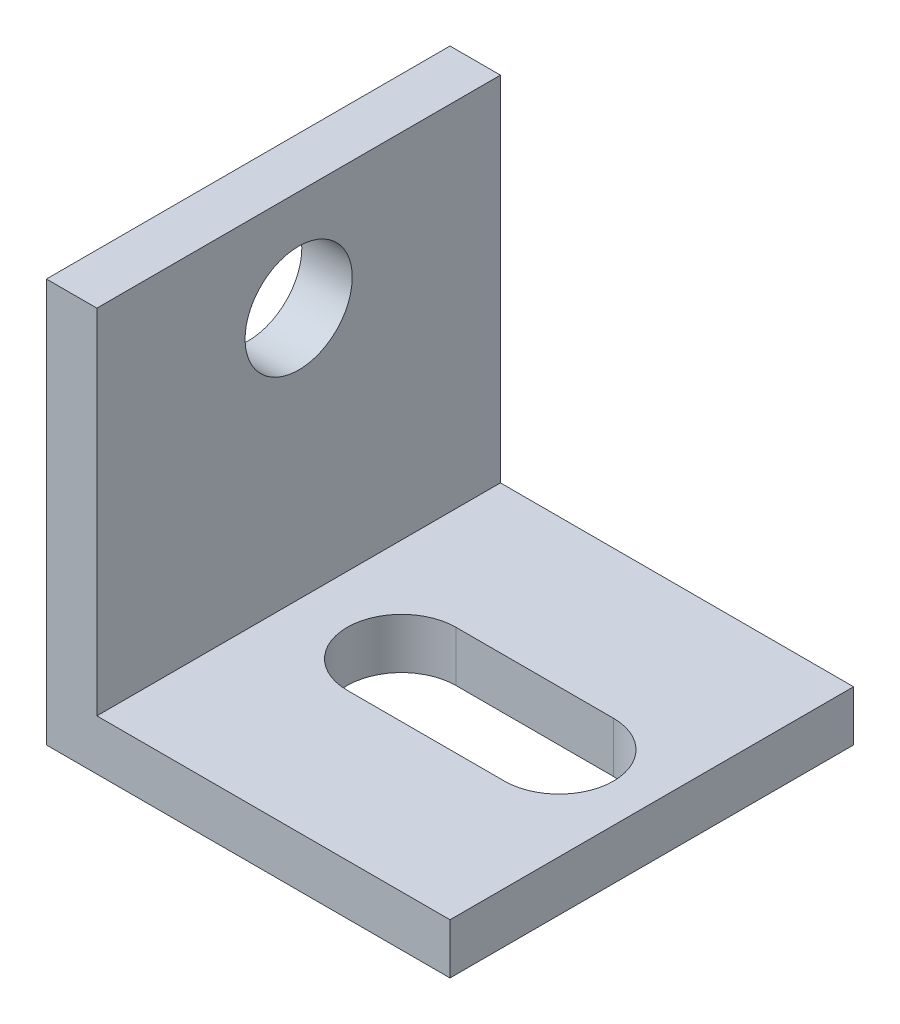
from build123d import *

# Parameters (mm, degrees)
BOSS_EXTRUDE1_DEPTH = 25.4
CUT_EXTRUDE1_DEPTH  = 25.4
SKETCH3_R           = 3.3734375
CUT_EXTRUDE2_DEPTH  = 25.4


with BuildPart() as part:
    # Sketch1 → Boss-Extrude1 (new body)
    with BuildSketch(Plane.XY):
        Polygon((0, 0), (0, 25.4), (3.175, 25.4), (3.175, 3.175), (25.4, 3.175), (25.4, 0), align=None)
    extrude(amount=BOSS_EXTRUDE1_DEPTH)

    # Sketch2 → Cut-Extrude1 (cut)
    with BuildSketch(Plane(origin=(0, 3.175, 0), x_dir=(1, 0, 0), z_dir=(0, 1, 0))):
        with BuildLine():
            Line((9.652, -9.271), (19.558, -9.271))
            ThreePointArc((19.558, -9.271), (22.987, -12.7), (19.558, -16.129))
            Line((19.558, -16.129), (9.652, -16.129))
            ThreePointArc((9.652, -16.129), (6.223, -12.7), (9.652, -9.271))
        make_face()
    extrude(amount=-CUT_EXTRUDE1_DEPTH, mode=Mode.SUBTRACT)

    # Sketch3 → Cut-Extrude2 (cut)
    with BuildSketch(Plane(origin=(3.175, 0, 0), x_dir=(0, 0, -1), z_dir=(1, 0, 0))):
        with Locations((-12.7, 19.05)):
            Circle(SKETCH3_R)
    extrude(amount=-CUT_EXTRUDE2_DEPTH, mode=Mode.SUBTRACT)


solid = part.part
